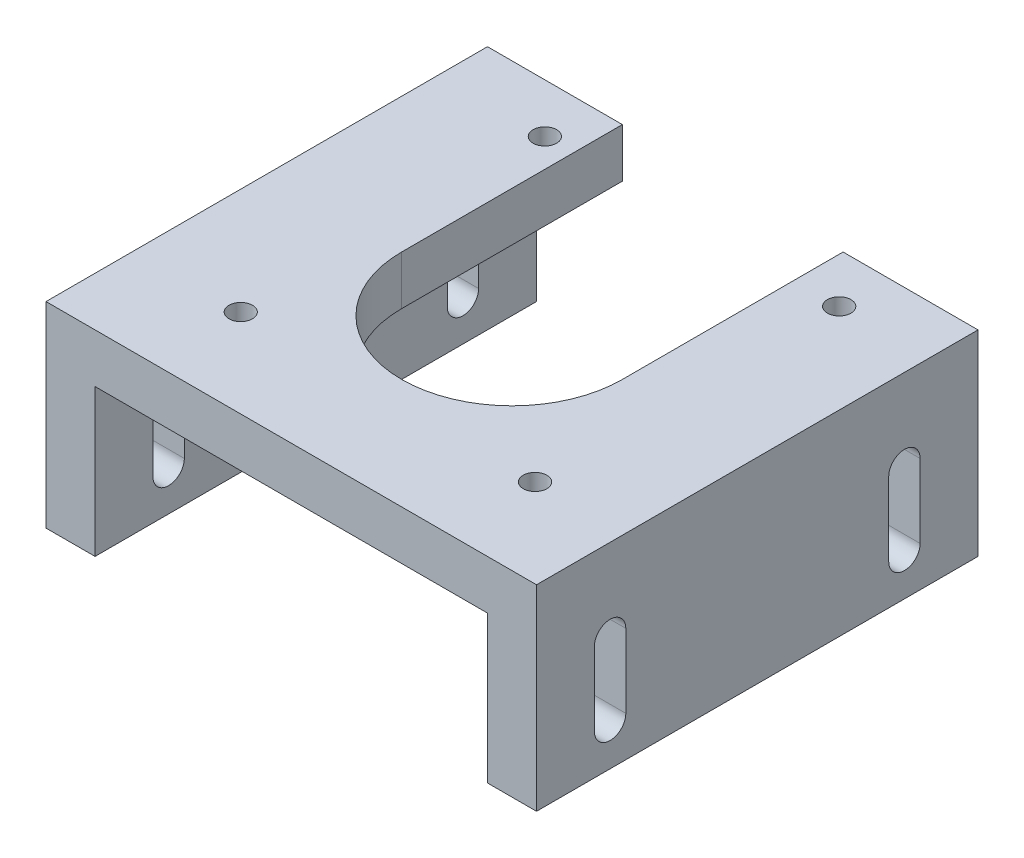
from build123d import *

# Parameters (mm, degrees)
BOSS_EXTRUDE1_DEPTH     = 45
CUT_EXTRUDE1_REACH      = 22
SKETCH3_R               = 1.2
CUT_EXTRUDE2_DEPTH      = 10
CUT_EXTRUDE3_DEPTH      = 1
CUT_EXTRUDE3_DEPTH_BACK = 51


with BuildPart() as part:
    # Sketch1 → Boss-Extrude1 (new body)
    with BuildSketch(Plane.XY):
        Polygon((-25, 0), (-20, 0), (-20, 15), (20, 15), (20, 0), (25, 0), (25, 20), (-25, 20), align=None)
    extrude(amount=BOSS_EXTRUDE1_DEPTH)

    # Sketch2 → Cut-Extrude1 (cut, up to next)
    with BuildSketch(Plane(origin=(0, 20, 0), x_dir=(1, 0, 0), z_dir=(0, 1, 0)), mode=Mode.PRIVATE) as cut_extrude1_sk1:
        with BuildLine():
            Line((11.25, 0), (11.25, -22.5))
            ThreePointArc((11.25, -22.5), (0, -33.75), (-11.25, -22.5))
            Line((-11.25, -22.5), (-11.25, 0))
            Line((-11.25, 0), (11.25, 0))
        make_face()
    cut_extrude1_tool1 = extrude(cut_extrude1_sk1.sketch, amount=-CUT_EXTRUDE1_REACH, mode=Mode.PRIVATE) & part.part
    add(cut_extrude1_tool1.solids().sort_by_distance((0, 20, 15.768467))[0], mode=Mode.SUBTRACT)

    # Sketch3 → Cut-Extrude2 (cut)
    with BuildSketch(Plane(origin=(0, 20, 0), x_dir=(1, 0, 0), z_dir=(0, 1, 0))):
        with Locations((15.85, -36)):
            Circle(SKETCH3_R)
        with Locations((-14.15, -36)):
            Circle(SKETCH3_R)
        with Locations((-14.15, -5)):
            Circle(SKETCH3_R)
        with Locations((15.85, -5)):
            Circle(SKETCH3_R)
    extrude(amount=-CUT_EXTRUDE2_DEPTH, mode=Mode.SUBTRACT)

    # Sketch4 → Cut-Extrude3 (cut, two sides)
    with BuildSketch(Plane(origin=(25, 0, 0), x_dir=(0, 0, -1), z_dir=(1, 0, 0))) as cut_extrude3_sk:
        with BuildLine():
            Line((-35.9, 11.6), (-35.9, 4.1))
            ThreePointArc((-35.9, 4.1), (-37.5, 2.5), (-39.1, 4.1))
            Line((-39.1, 4.1), (-39.1, 11.6))
            ThreePointArc((-39.1, 11.6), (-37.5, 13.2), (-35.9, 11.6))
        make_face()
        with BuildLine():
            Line((-9.1, 11.6), (-9.1, 4.1))
            ThreePointArc((-9.1, 4.1), (-7.5, 2.5), (-5.9, 4.1))
            Line((-5.9, 4.1), (-5.9, 11.6))
            ThreePointArc((-5.9, 11.6), (-7.5, 13.2), (-9.1, 11.6))
        make_face()
    extrude(amount=CUT_EXTRUDE3_DEPTH, mode=Mode.SUBTRACT)
    extrude(cut_extrude3_sk.sketch, amount=-CUT_EXTRUDE3_DEPTH_BACK, mode=Mode.SUBTRACT)


solid = part.part
